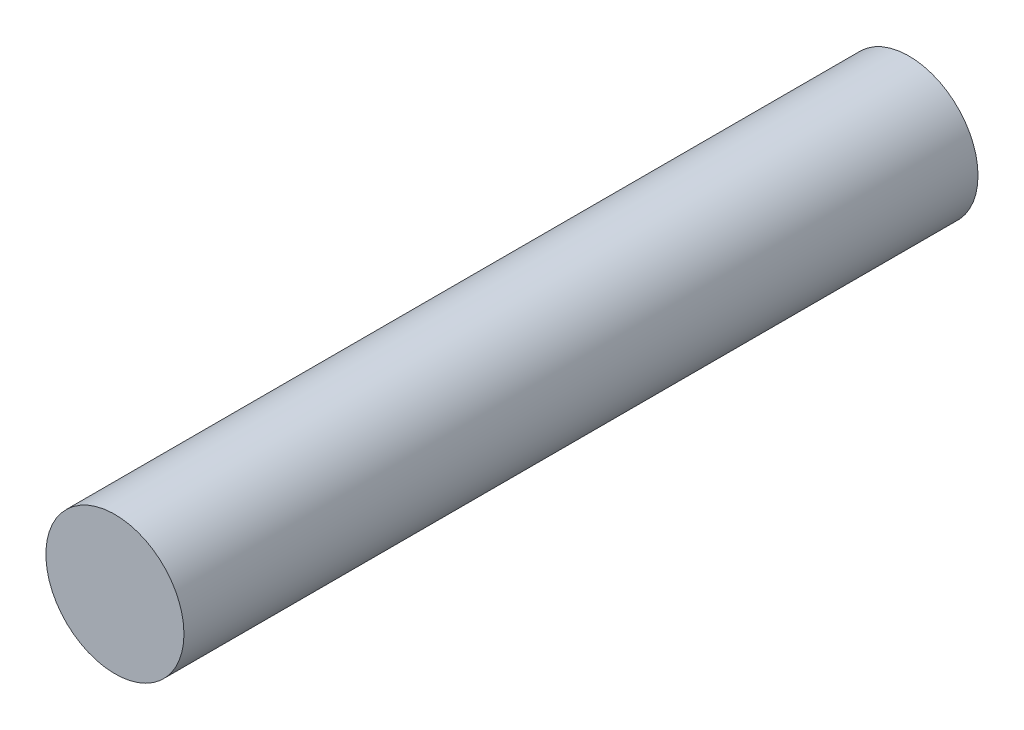
from build123d import *

# Parameters (mm, degrees)
SKETCH1_R           = 10
BOSS_EXTRUDE1_DEPTH = 115
SKETCH3_R           = 5.08
CUT_EXTRUDE1_DEPTH  = 2.54


with BuildPart() as part:
    # Sketch1 → Boss-Extrude1 (new body)
    with BuildSketch(Plane.XY):
        Circle(SKETCH1_R)
    extrude(amount=BOSS_EXTRUDE1_DEPTH)

    # Sketch3 → Cut-Extrude1 (cut)
    with BuildSketch(Plane(origin=(0, 0, 0), x_dir=(-1, 0, 0), z_dir=(0, 0, -1))):
        Circle(SKETCH3_R)
    extrude(amount=-CUT_EXTRUDE1_DEPTH, mode=Mode.SUBTRACT)


solid = part.part
